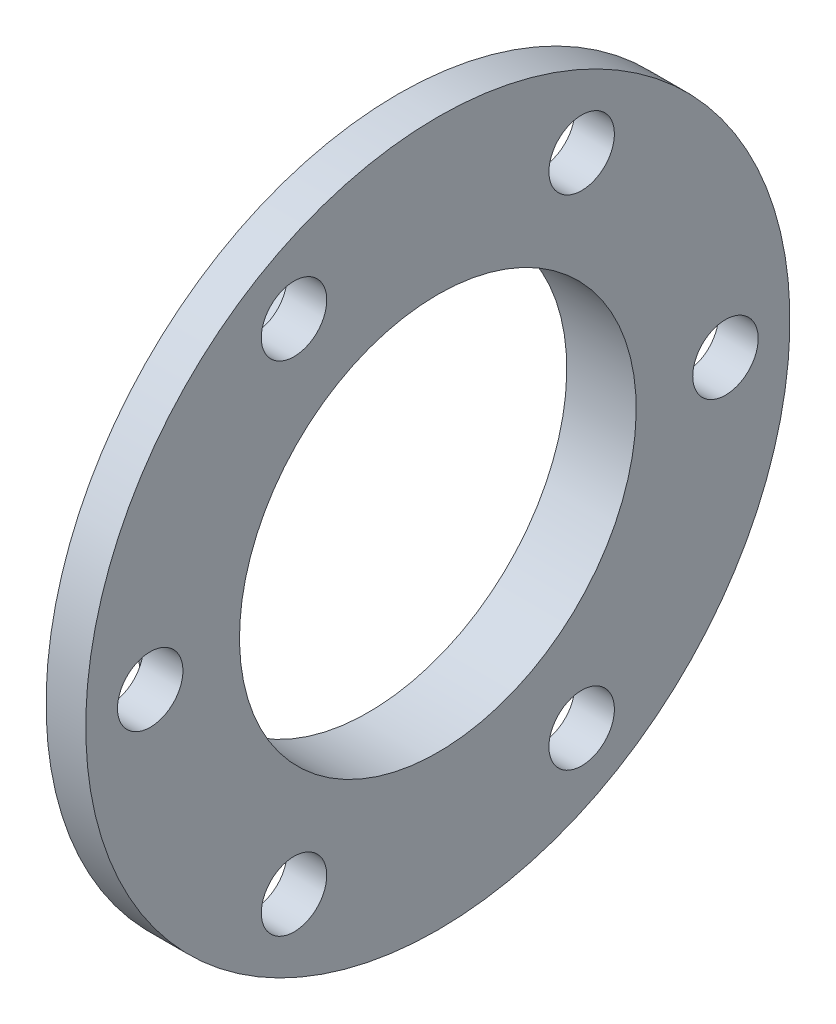
from build123d import *

# Parameters (mm, degrees)
M6_CLEARANCE_HOLE1_D     = 6.6
M6_CLEARANCE_HOLE1_DEPTH = 4
CIRPATTERN1_COUNT        = 6


with BuildPart() as part:
    # Sketch2 → Revolve1 (revolve)
    with BuildSketch(Plane.XY):
        Polygon((-7, 23.5), (-7, 20), (0, 20), (0, 35.5), (-4, 35.5), (-4, 23.5), align=None)
    revolve(axis=Axis((0, 0, 0), (-1, 0, 0)))

    # M6 Clearance Hole1
    with Locations(Plane(origin=(-4, 0, -29), x_dir=(0, -1, 0), z_dir=(-1, 0, 0))):
        with Locations((0, 0)):
            m6_clearance_hole1 = Hole(M6_CLEARANCE_HOLE1_D / 2, depth=M6_CLEARANCE_HOLE1_DEPTH)

    # CirPattern1: M6 Clearance Hole1 ×6 about axis
    cirpattern1_axis = Axis((0, 0, 0), (1, 0, 0))
    for i in range(1, CIRPATTERN1_COUNT):
        add(m6_clearance_hole1.rotate(cirpattern1_axis, i * 360 / CIRPATTERN1_COUNT), mode=Mode.SUBTRACT)


solid = part.part
